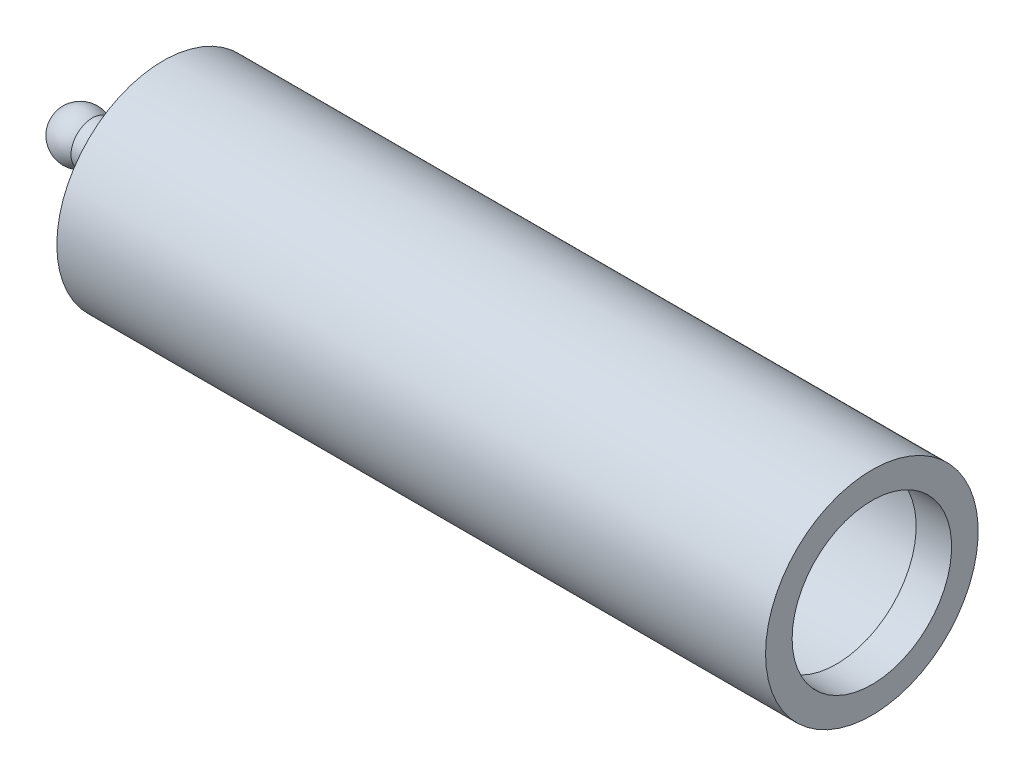
from build123d import *


with BuildPart() as part:
    # Sketch1 → Revolve1 (revolve)
    with BuildSketch(Plane.XY):
        Polygon((220, 45), (220, 60), (-180, 60), (-180, 12), (-220, 12), (-220, 0), (-160, 0), (-160, 55), (200, 55), (200, 45), align=None)
    revolve(axis=Axis((-220, 0, 0), (1, 0, 0)))

    # Sketch2 → Ball (revolve)
    with BuildSketch(Plane.XY):
        with BuildLine():
            Line((-240.493320132, 0), (-212.973320132, 0))
            ThreePointArc((-212.973320132, 0), (-226.733320132, 13.76), (-240.493320132, 0))
        make_face()
    revolve(axis=Axis((-240.493320132, 0, 0), (1, 0, 0)))


solid = part.part
